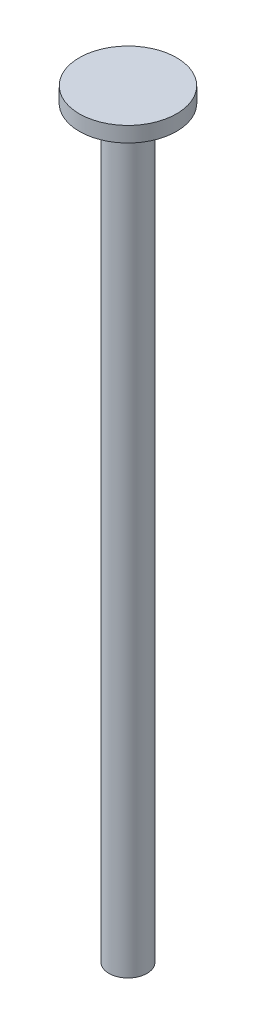
from build123d import *

# Parameters (mm, degrees)
SKETCH1_R           = 2
BOSS_EXTRUDE1_DEPTH = 78
SKETCH2_R           = 5.1
BOSS_EXTRUDE2_DEPTH = 1.6


with BuildPart() as part:
    # Sketch1 → Boss-Extrude1 (new body)
    with BuildSketch(Plane(origin=(0, 0, 0), x_dir=(1, 0, 0), z_dir=(0, 1, 0))):
        Circle(SKETCH1_R)
    extrude(amount=BOSS_EXTRUDE1_DEPTH)

    # Sketch2 → Boss-Extrude2 (add)
    with BuildSketch(Plane(origin=(0, 78, 0), x_dir=(1, 0, 0), z_dir=(0, 1, 0))):
        Circle(SKETCH2_R)
    extrude(amount=BOSS_EXTRUDE2_DEPTH)


solid = part.part
